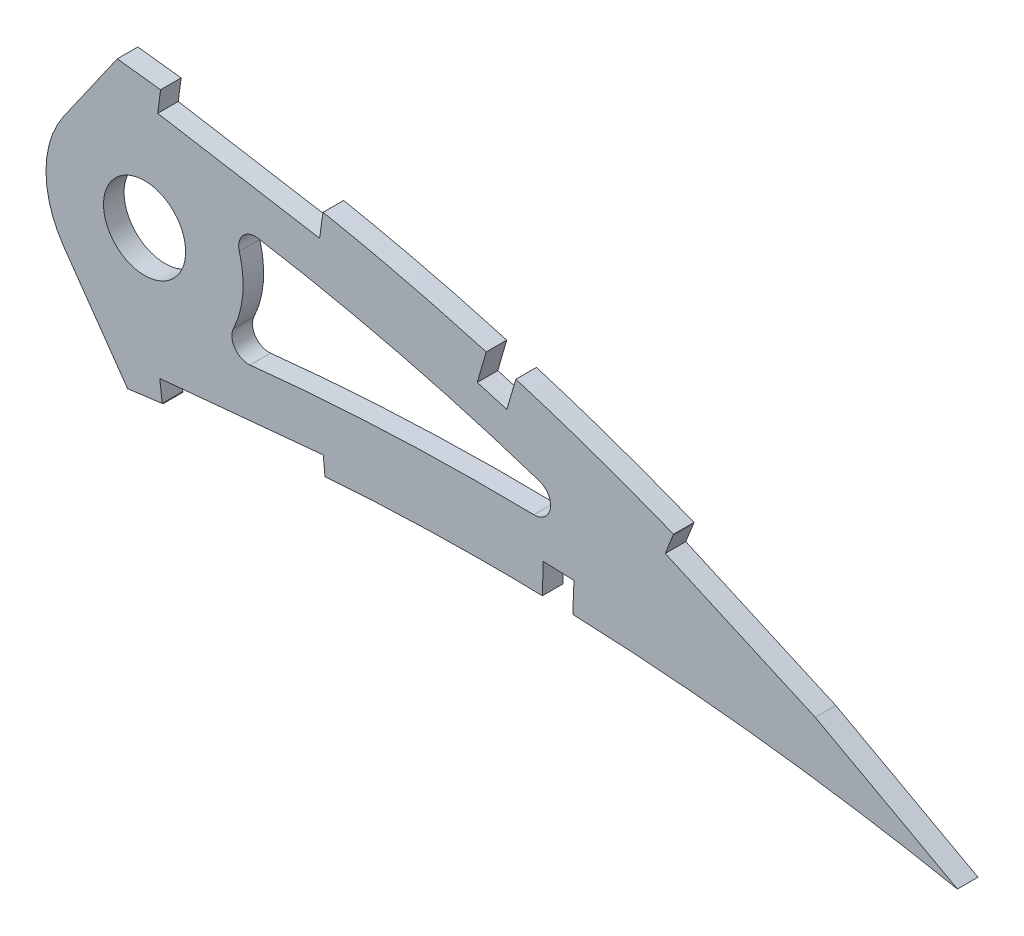
from build123d import *

# Parameters (mm, degrees)
BOSS_EXTRUDE1_DEPTH = 3.175
SKETCH3_R           = 6.35
CUT_EXTRUDE2_DEPTH  = 7.62
CUT_EXTRUDE3_DEPTH  = 425.770685521
CUT_EXTRUDE4_DEPTH  = 425.054471104
FILLET1_R           = 2.54


with BuildPart() as part:
    # Sketch1 → Boss-Extrude1 (new body)
    with BuildSketch(Plane.XY):
        with BuildLine():
            Line((417.491116248, -0.651692804), (421.450974812, -1.472467044))
            Line((421.450974812, -1.472467044), (418.012470552, 0.651692804))
            add(Edge.make_bspline(
                [(418.012470552, 0.651692804), (417.98044815, 0.671474864), (417.852482746, 0.75052638), (417.564153255, 0.927383578), (417.084024874, 1.221948394), (416.411887136, 1.63217468), (415.548261806, 2.156972941), (414.492714479, 2.792668486), (413.245904156, 3.537195961), (411.808132787, 4.387034494), (410.179547234, 5.338203991), (408.360768057, 6.386852134), (406.351953186, 7.52704122), (404.153880987, 8.754112876), (401.767305606, 10.062231026), (399.19267854, 11.445487716), (396.430921499, 12.896846477), (393.483094762, 14.410065077), (390.349735958, 15.976787411), (387.032322118, 17.590492828), (383.53195848, 19.243135295), (379.849840019, 20.925898146), (375.98808191, 22.631921026), (371.947751923, 24.35059805), (367.731152528, 26.074482818), (363.340078768, 27.793764201), (358.777130588, 29.500612257), (354.044068493, 31.183969527), (349.144430575, 32.836479872), (344.080593504, 34.447407706), (338.856178603, 36.008004406), (333.474221444, 37.508151761), (327.939208494, 38.940156234), (322.254650095, 40.293589254), (316.425364207, 41.559391603), (310.455984511, 42.72994226), (304.351517267, 43.793554912), (298.12887857, 44.749400354), (291.888189265, 45.544501897), (285.660339717, 46.324314327), (279.441765017, 47.05687676), (273.147186285, 47.758406613), (266.78265934, 48.424954116), (260.354497207, 49.054435041), (253.869207533, 49.644132572), (247.333529654, 50.192317352), (240.75378784, 50.695883209), (234.13692006, 51.154054264), (227.48946797, 51.562802699), (220.818511901, 51.921821557), (214.130823757, 52.228606963), (207.433363169, 52.481045058), (200.733241899, 52.677611966), (194.03741489, 52.816424499), (187.353132032, 52.896609907), (180.687346008, 52.915977167), (174.047303325, 52.874179852), (167.439957194, 52.769782806), (160.872561498, 52.601356868), (154.352078932, 52.36858769), (147.885560384, 52.071576223), (141.480086041, 51.707835252), (135.142604697, 51.279682727), (128.880173648, 50.78532016), (122.699673543, 50.224616012), (116.607581601, 49.599907517), (110.610680398, 48.90949561), (104.715396798, 48.155344678), (98.928179068, 47.338933301), (93.255520599, 46.45981687), (87.703498103, 45.520534547), (82.278103773, 44.522047456), (76.985077668, 43.467282827), (71.830182495, 42.356515787), (66.818874958, 41.193078409), (61.956363154, 39.97899758), (57.247874135, 38.716495991), (52.698180969, 37.408603084), (48.311884381, 36.058286041), (44.094097756, 34.667028605), (40.048008795, 33.240105797), (36.178587704, 31.778530584), (32.488798598, 30.286805616), (28.982965605, 28.766967771), (25.66370775, 27.223650228), (22.534781646, 25.658610062), (19.59841729, 24.076231981), (16.857562593, 22.478942324), (14.314855879, 20.869707996), (11.971365892, 19.2526108), (9.830323596, 17.628665848), (7.892464518, 16.001976699), (6.159015004, 14.37502038), (4.632452775, 12.748917707), (3.312722951, 11.12653219), (2.201555106, 9.509148701), (1.299141963, 7.898297704), (0.607524637, 6.295149332), (0.126017388, 4.70060514), (-0.137556514, 3.117018659), (-0.203161624, 1.54312034), (-0.067619355, 0.51360488), (0, 0)],
                knots=[0, 0, 0, 0, 0.00025409, 0.001015373, 0.002283359, 0.004056577, 0.006330981, 0.009105275, 0.01237449, 0.016134023, 0.020379661, 0.025105976, 0.030306237, 0.035972206, 0.042099523, 0.048678063, 0.055701664, 0.063160184, 0.071045824, 0.079349826, 0.08806291, 0.097175756, 0.106678112, 0.116561573, 0.126814275, 0.137428301, 0.148393618, 0.15969976, 0.171338125, 0.183297699, 0.195569604, 0.208143556, 0.221011593, 0.234161831, 0.24758745, 0.261276822, 0.27522271, 0.289414144, 0.3037712, 0.317689227, 0.331784111, 0.346039677, 0.36044387, 0.37498272, 0.389640454, 0.404403317, 0.419256601, 0.434186749, 0.449177265, 0.464214782, 0.479284009, 0.49436974, 0.509457833, 0.524532346, 0.53957932, 0.554582984, 0.569529546, 0.584403417, 0.599190992, 0.613876838, 0.628447475, 0.642888675, 0.657186054, 0.671325546, 0.685294014, 0.699078147, 0.712665095, 0.726042645, 0.739197713, 0.752117586, 0.764792042, 0.777208152, 0.789355685, 0.80122396, 0.812803686, 0.824082909, 0.835054602, 0.845709571, 0.856037853, 0.866033834, 0.875688843, 0.884997719, 0.893953426, 0.902552897, 0.910789386, 0.918660734, 0.926166253, 0.933302626, 0.94007122, 0.94647478, 0.952517526, 0.958204819, 0.963546652, 0.9685566, 0.973249913, 0.977651041, 0.981787043, 0.985694226, 0.989415109, 0.993001157, 0.996508416, 1, 1, 1, 1], degree=3))
            add(Edge.make_bspline(
                [(0, 0), (0.107344122, -0.506735851), (0.322525701, -1.522536416), (0.907145976, -2.98486836), (1.680278374, -4.390592942), (2.658149173, -5.735976229), (3.834256448, -7.020650547), (5.206002713, -8.245952015), (6.772042592, -9.411221952), (8.530326502, -10.515929932), (10.478300238, -11.56124868), (12.613774275, -12.546528288), (14.934801506, -13.471460836), (17.438853083, -14.334810006), (20.122867794, -15.137890506), (22.984293745, -15.87874546), (26.019877259, -16.558410209), (29.226698653, -17.175149915), (32.601263508, -17.729591078), (36.140066093, -18.221423529), (39.839474107, -18.650954746), (43.695858135, -19.017283569), (47.705403835, -19.321197808), (51.864114831, -19.562899166), (56.167954337, -19.743154049), (60.612799743, -19.861277173), (65.194297816, -19.919110149), (69.90830817, -19.917521134), (74.750219376, -19.856085207), (79.715895302, -19.738196204), (84.800570833, -19.563107476), (89.999655516, -19.33293774), (95.308459722, -19.050003416), (100.722222022, -18.715263595), (106.236178133, -18.330201822), (111.845540422, -17.897906181), (117.545213296, -17.419454845), (123.330225884, -16.897636702), (129.195456677, -16.33506396), (135.135838219, -15.733517171), (141.146127059, -15.095825988), (147.22096994, -14.424056849), (153.355199033, -13.721793599), (159.543210771, -12.990306925), (165.779772492, -12.233773195), (172.059017171, -11.453637843), (178.375694094, -10.652905812), (184.724121999, -9.835347203), (191.098357706, -9.000868908), (197.493040005, -8.155416157), (203.902002084, -7.29829268), (210.319665377, -6.433906623), (216.740089126, -5.564944849), (223.157019771, -4.691674703), (229.564816603, -3.817715282), (235.957535291, -2.945465763), (242.328914049, -2.075005893), (248.673188486, -1.210662101), (254.983970072, -0.352328891), (261.255439585, 0.498253703), (267.481587275, 1.33854664), (273.656539031, 2.167489343), (279.773925067, 2.98455751), (285.827590721, 3.790057847), (291.72081698, 4.559541474), (297.438204766, 5.333983617), (302.999020517, 5.96885451), (308.4905971, 6.510739718), (313.918638837, 6.955010775), (319.276627913, 7.30805944), (324.558425157, 7.572408429), (329.75773577, 7.751748326), (334.867992319, 7.851399579), (339.882811875, 7.873890942), (344.79534958, 7.826395206), (349.599216077, 7.712740899), (354.287706783, 7.538029372), (358.854280799, 7.308155071), (363.292451785, 7.029384641), (367.595556763, 6.705830062), (371.757599447, 6.34504489), (375.772158368, 5.952310734), (379.633069209, 5.532114413), (383.334698301, 5.093260959), (386.871120866, 4.638639591), (390.237017411, 4.175721536), (393.426969843, 3.709197789), (396.435926147, 3.245024667), (399.259158851, 2.787630174), (401.892107523, 2.343085233), (404.330647739, 1.915543252), (406.570547937, 1.509179531), (408.608700706, 1.129121201), (410.44108076, 0.777256216), (412.065237404, 0.459383467), (413.478150672, 0.176905414), (414.67774925, -0.066198026), (415.661938268, -0.268967448), (416.429222922, -0.428074261), (416.978087732, -0.54377272), (417.307939008, -0.612619163), (417.454496179, -0.643881356), (417.491116248, -0.651692804)],
                knots=[0, 0, 0, 0, 0.003638255, 0.007293231, 0.011028136, 0.014901081, 0.018963272, 0.023258475, 0.027820626, 0.032679082, 0.03785316, 0.043361875, 0.049214679, 0.055422346, 0.061988786, 0.068918036, 0.076211157, 0.083868392, 0.091887411, 0.100265912, 0.108999867, 0.118084529, 0.127514843, 0.13728527, 0.147387917, 0.157816481, 0.168563473, 0.179619128, 0.190977373, 0.202626974, 0.214560478, 0.226767249, 0.239236417, 0.251959004, 0.264923894, 0.278119703, 0.291536035, 0.30516028, 0.318980685, 0.332985499, 0.34716279, 0.361498603, 0.375980747, 0.390597192, 0.405332593, 0.420174823, 0.435109533, 0.450124276, 0.465203068, 0.480333154, 0.495500583, 0.510689775, 0.525887334, 0.541078314, 0.556247233, 0.571381784, 0.58646604, 0.601484516, 0.616424329, 0.631269422, 0.646006524, 0.660620684, 0.675098187, 0.689422858, 0.703581825, 0.716907563, 0.730009275, 0.742952128, 0.755725558, 0.768319952, 0.780724338, 0.792926529, 0.804916041, 0.816679084, 0.828203524, 0.8394749, 0.850481359, 0.861207697, 0.871639326, 0.881763414, 0.891563605, 0.901027365, 0.910138977, 0.918883977, 0.927249278, 0.935221104, 0.942784738, 0.949928188, 0.956638464, 0.962904203, 0.968712288, 0.974054485, 0.978918432, 0.983297218, 0.987180246, 0.990560674, 0.993433357, 0.995790625, 0.997629587, 0.998945816, 0.999736592, 1, 1, 1, 1], degree=3))
        make_face()
    extrude(amount=BOSS_EXTRUDE1_DEPTH)

    # Sketch3 → Cut-Extrude2 (cut)
    with BuildSketch(Plane(origin=(0, 0, 0), x_dir=(-1, 0, 0), z_dir=(0, 0, -1))):
        with Locations((-285.729166098, 26.255421435)):
            Circle(SKETCH3_R)
    extrude(amount=-CUT_EXTRUDE2_DEPTH, mode=Mode.SUBTRACT)

    # Sketch4 → Cut-Extrude3 (cut, through all)
    with BuildSketch(Plane.XY.offset(3.175)):
        with BuildLine():
            ThreePointArc((273.245288943, 17.514116545), (270.489166098, 26.255421435), (273.245288943, 34.996726325))
            Line((273.245288943, 34.996726325), (274.886273897, 37.340295715))
            Line((274.886273897, 37.340295715), (281.517132997, 46.810143922))
            add(Edge.make_bspline(
                [(281.517132997, 46.810143922), (280.833063767, 46.890035279), (278.05111843, 47.211864113), (273.147186285, 47.758406613), (266.78265934, 48.424954116), (260.354497207, 49.054435041), (253.869207533, 49.644132572), (247.333529654, 50.192317352), (240.75378784, 50.695883209), (234.13692006, 51.154054264), (227.48946797, 51.562802699), (220.818511901, 51.921821557), (214.130823757, 52.228606963), (207.433363169, 52.481045058), (200.733241899, 52.677611966), (194.03741489, 52.816424499), (187.353132032, 52.896609907), (180.687346008, 52.915977167), (174.047303325, 52.874179852), (167.439957194, 52.769782806), (160.872561498, 52.601356868), (155.481659891, 52.408911643), (152.280960421, 52.270445439), (151.253871268, 52.223436592)],
                knots=[0.32713491, 0.32713491, 0.32713491, 0.32713491, 0.331784111, 0.346039677, 0.36044387, 0.37498272, 0.389640454, 0.404403317, 0.419256601, 0.434186749, 0.449177265, 0.464214782, 0.479284009, 0.49436974, 0.509457833, 0.524532346, 0.53957932, 0.554582984, 0.569529546, 0.584403417, 0.599190992, 0.613876838, 0.620817468, 0.620817468, 0.620817468, 0.620817468], degree=3))
            add(Edge.make_bspline(
                [(151.253871268, 52.223436592), (150.124766545, 52.171758595), (146.859034641, 52.01328398), (141.480086041, 51.707835252), (135.142604697, 51.279682727), (128.880173648, 50.78532016), (122.699673543, 50.224616012), (116.607581601, 49.599907517), (110.610680398, 48.90949561), (104.715396798, 48.155344678), (98.928179068, 47.338933301), (93.255520599, 46.45981687), (87.703498103, 45.520534547), (82.278103773, 44.522047456), (76.985077668, 43.467282827), (71.830182495, 42.356515787), (66.818874958, 41.193078409), (61.956363154, 39.97899758), (57.247874135, 38.716495991), (52.698180969, 37.408603084), (48.311884381, 36.058286041), (44.094097756, 34.667028605), (40.048008795, 33.240105797), (36.178587704, 31.778530584), (32.488798598, 30.286805616), (28.982965605, 28.766967771), (25.66370775, 27.223650228), (22.534781646, 25.658610062), (19.59841729, 24.076231981), (16.857562593, 22.478942324), (14.314855879, 20.869707996), (11.971365892, 19.2526108), (9.830323596, 17.628665848), (7.892464518, 16.001976699), (6.159015004, 14.37502038), (4.632452775, 12.748917707), (3.312722951, 11.12653219), (2.201555106, 9.509148701), (1.299141963, 7.898297704), (0.607524637, 6.295149332), (0.126017388, 4.70060514), (-0.137556514, 3.117018659), (-0.203161624, 1.54312034), (-0.067619355, 0.51360488), (0, 0)],
                knots=[0.620817468, 0.620817468, 0.620817468, 0.620817468, 0.628447475, 0.642888675, 0.657186054, 0.671325546, 0.685294014, 0.699078147, 0.712665095, 0.726042645, 0.739197713, 0.752117586, 0.764792042, 0.777208152, 0.789355685, 0.80122396, 0.812803686, 0.824082909, 0.835054602, 0.845709571, 0.856037853, 0.866033834, 0.875688843, 0.884997719, 0.893953426, 0.902552897, 0.910789386, 0.918660734, 0.926166253, 0.933302626, 0.94007122, 0.94647478, 0.952517526, 0.958204819, 0.963546652, 0.9685566, 0.973249913, 0.977651041, 0.981787043, 0.985694226, 0.989415109, 0.993001157, 0.996508416, 1, 1, 1, 1], degree=3))
            add(Edge.make_bspline(
                [(0, 0), (0.107344122, -0.506735851), (0.322525701, -1.522536416), (0.907145976, -2.98486836), (1.680278374, -4.390592942), (2.658149173, -5.735976229), (3.834256448, -7.020650547), (5.206002713, -8.245952015), (6.772042592, -9.411221952), (8.530326502, -10.515929932), (10.478300238, -11.56124868), (12.613774275, -12.546528288), (14.934801506, -13.471460836), (17.438853083, -14.334810006), (20.122867794, -15.137890506), (22.984293745, -15.87874546), (26.019877259, -16.558410209), (29.226698653, -17.175149915), (32.601263508, -17.729591078), (36.140066093, -18.221423529), (39.839474107, -18.650954746), (43.695858135, -19.017283569), (47.705403835, -19.321197808), (51.864114831, -19.562899166), (56.167954337, -19.743154049), (60.612799743, -19.861277173), (65.194297816, -19.919110149), (69.90830817, -19.917521134), (74.750219376, -19.856085207), (79.715895302, -19.738196204), (84.800570833, -19.563107476), (89.999655516, -19.33293774), (95.308459722, -19.050003416), (100.722222022, -18.715263595), (106.236178133, -18.330201822), (111.845540422, -17.897906181), (117.545213296, -17.419454845), (123.330225884, -16.897636702), (129.195456677, -16.33506396), (135.135838219, -15.733517171), (141.146127059, -15.095825988), (147.22096994, -14.424056849), (153.355199033, -13.721793599), (159.543210771, -12.990306925), (165.779772492, -12.233773195), (172.059017171, -11.453637843), (176.943047577, -10.834514903), (179.733508183, -10.477064851), (180.418148813, -10.389136696)],
                knots=[0, 0, 0, 0, 0.003638255, 0.007293231, 0.011028136, 0.014901081, 0.018963272, 0.023258475, 0.027820626, 0.032679082, 0.03785316, 0.043361875, 0.049214679, 0.055422346, 0.061988786, 0.068918036, 0.076211157, 0.083868392, 0.091887411, 0.100265912, 0.108999867, 0.118084529, 0.127514843, 0.13728527, 0.147387917, 0.157816481, 0.168563473, 0.179619128, 0.190977373, 0.202626974, 0.214560478, 0.226767249, 0.239236417, 0.251959004, 0.264923894, 0.278119703, 0.291536035, 0.30516028, 0.318980685, 0.332985499, 0.34716279, 0.361498603, 0.375980747, 0.390597192, 0.405332593, 0.420174823, 0.435109533, 0.439965351, 0.439965351, 0.439965351, 0.439965351], degree=3))
            add(Edge.make_bspline(
                [(180.418148813, -10.389136696), (181.850495116, -10.205180963), (185.408545914, -9.745746359), (191.098357706, -9.000868908), (197.493040005, -8.155416157), (203.902002084, -7.29829268), (210.319665377, -6.433906623), (216.740089126, -5.564944849), (223.157019771, -4.691674703), (229.564816603, -3.817715282), (235.957535291, -2.945465763), (242.328914049, -2.075005893), (248.673188486, -1.210662101), (254.983970072, -0.352328891), (261.255439585, 0.498253703), (267.481587275, 1.33854664), (273.656539031, 2.167489343), (278.85986366, 2.862470972), (282.004212477, 3.281215433), (283.108625896, 3.427811537)],
                knots=[0.439965351, 0.439965351, 0.439965351, 0.439965351, 0.450124276, 0.465203068, 0.480333154, 0.495500583, 0.510689775, 0.525887334, 0.541078314, 0.556247233, 0.571381784, 0.58646604, 0.601484516, 0.616424329, 0.631269422, 0.646006524, 0.660620684, 0.675098187, 0.682935578, 0.682935578, 0.682935578, 0.682935578], degree=3))
            Line((283.108625896, 3.427811537), (276.543076139, 12.804388335))
            Line((276.543076139, 12.804388335), (273.245288943, 17.514116545))
        make_face()
        with BuildLine():
            add(Edge.make_bspline(
                [(362.352770137, 17.265342245), (359.116729683, 18.538986422), (350.651628268, 21.70312526), (336.76245738, 26.184380092), (323.325821889, 29.685457962), (312.46520361, 32.017125458), (305.650127669, 33.271885786), (301.010448964, 34.024743586), (299.133105649, 34.309199759), (298.619492426, 34.385432945)],
                knots=[0.130937261, 0.130937261, 0.130937261, 0.130937261, 0.155204367, 0.194005459, 0.23280655, 0.252207096, 0.271607642, 0.281307915, 0.284959903, 0.284959903, 0.284959903, 0.284959903], degree=3))
            ThreePointArc((298.619492426, 34.385432945), (300.369968215, 30.486793952), (300.969166098, 26.255421435))
            ThreePointArc((300.969166098, 26.255421435), (299.795673281, 20.391039483), (296.455914698, 15.429782217))
            add(Edge.make_bspline(
                [(296.455914698, 15.429782217), (296.825227638, 15.475634747), (298.474939021, 15.677515554), (301.393417945, 16.007171577), (306.480644201, 16.530089608), (315.428804381, 17.299112469), (328.220882032, 17.971225759), (343.594122404, 18.103863059), (354.969060254, 17.713169544), (361.214906663, 17.338809272), (362.352770137, 17.265342245)],
                knots=[0.717454935, 0.717454935, 0.717454935, 0.717454935, 0.719982675, 0.728733217, 0.737483758, 0.754984841, 0.789987006, 0.824989172, 0.859991338, 0.867792259, 0.867792259, 0.867792259, 0.867792259], degree=3))
        make_face()
    extrude(amount=-CUT_EXTRUDE3_DEPTH, mode=Mode.SUBTRACT)

    # Sketch5 → Cut-Extrude4 (cut, through all)
    with BuildSketch(Plane.XY.offset(3.175)):
        Polygon((288.173393603, 45.776362445), (287.759757849, 42.628902416), (312.792499178, 38.415705127), (313.227372719, 41.560689534), align=None)
        with BuildLine():
            Line((288.173393603, 45.776362445), (313.227372719, 41.560689534))
            Line((313.227372719, 41.560689534), (313.328431792, 42.161289238))
            add(Edge.make_bspline(
                [(313.328431792, 42.161289238), (312.382989688, 42.346109453), (309.407146517, 42.912686686), (304.351517267, 43.793554912), (298.12887857, 44.749400354), (292.727075643, 45.437622701), (289.410209047, 45.854407815), (288.203335319, 46.004196602)],
                knots=[0.254773896, 0.254773896, 0.254773896, 0.254773896, 0.261276822, 0.27522271, 0.289414144, 0.3037712, 0.31198079, 0.31198079, 0.31198079, 0.31198079], degree=3))
            Line((288.203335319, 46.004196602), (288.173393603, 45.776362445))
        make_face()
        Polygon((338.492483544, 35.871521953), (337.163627429, 31.298701708), (341.736447673, 29.969845589), (343.074959745, 34.500474172), align=None)
        with BuildLine():
            add(Edge.make_bspline(
                [(343.139597857, 34.71926284), (341.727658162, 35.149647278), (340.19883062, 35.603476476), (338.6664674, 36.045065708), (338.55244266, 36.077851486)],
                knots=[0.185605426, 0.185605426, 0.185605426, 0.185605426, 0.195569604, 0.196370508, 0.196370508, 0.196370508, 0.196370508], degree=3))
            Line((338.55244266, 36.077851486), (338.492483544, 35.871521953))
            Line((338.492483544, 35.871521953), (343.074959745, 34.500474172))
            Line((343.074959745, 34.500474172), (343.139597857, 34.71926284))
        make_face()
        with BuildLine():
            Line((369.469556974, 31.05371971), (367.511679068, 26.149795466))
            add(Edge.make_bspline(
                [(418.012470552, 0.651692804), (417.98044815, 0.671474864), (417.852482746, 0.75052638), (417.564153255, 0.927383578), (417.084024874, 1.221948394), (416.411887136, 1.63217468), (415.548261806, 2.156972941), (414.492714479, 2.792668486), (413.245904156, 3.537195961), (411.808132787, 4.387034494), (410.179547234, 5.338203991), (408.360768057, 6.386852134), (406.351953186, 7.52704122), (404.153880987, 8.754112876), (401.767305606, 10.062231026), (399.19267854, 11.445487716), (396.430921499, 12.896846477), (393.483094762, 14.410065077), (390.349735958, 15.976787411), (387.032322118, 17.590492828), (383.53195848, 19.243135295), (379.849840019, 20.925898146), (375.98808191, 22.631921026), (371.947751923, 24.35059805), (369.098573745, 25.515435969), (367.599990275, 26.114537466), (367.511679068, 26.149795466)],
                knots=[0, 0, 0, 0, 0.00025409, 0.001015373, 0.002283359, 0.004056577, 0.006330981, 0.009105275, 0.01237449, 0.016134023, 0.020379661, 0.025105976, 0.030306237, 0.035972206, 0.042099523, 0.048678063, 0.055701664, 0.063160184, 0.071045824, 0.079349826, 0.08806291, 0.097175756, 0.106678112, 0.116561573, 0.126814275, 0.127456175, 0.127456175, 0.127456175, 0.127456175], degree=3))
            Line((418.012470552, 0.651692804), (421.450974812, -1.472467044))
            Line((421.450974812, -1.472467044), (417.491116248, -0.651692804))
            add(Edge.make_bspline(
                [(411.773701593, 0.515858534), (411.894185677, 0.492124414), (412.486090009, 0.375244103), (413.478150672, 0.176905414), (414.67774925, -0.066198026), (415.661938268, -0.268967448), (416.429222922, -0.428074261), (416.978087732, -0.54377272), (417.307939008, -0.612619163), (417.454496179, -0.643881356), (417.491116248, -0.651692804)],
                knots=[0.986316385, 0.986316385, 0.986316385, 0.986316385, 0.987180246, 0.990560674, 0.993433357, 0.995790625, 0.997629587, 0.998945816, 0.999736592, 1, 1, 1, 1], degree=3))
            Line((411.773701593, 0.515858534), (411.720148616, 0.417696682))
            Line((411.720148616, 0.417696682), (430.865990346, -10.027469171))
            Line((430.865990346, -10.027469171), (430.865990346, 31.05371971))
            Line((430.865990346, 31.05371971), (369.469556974, 31.05371971))
        make_face()
        with BuildLine():
            add(Edge.make_bspline(
                [(418.012470552, 0.651692804), (417.98044815, 0.671474864), (417.852482746, 0.75052638), (417.564153255, 0.927383578), (417.084024874, 1.221948394), (416.411887136, 1.63217468), (415.548261806, 2.156972941), (414.492714479, 2.792668486), (413.245904156, 3.537195961), (411.808132787, 4.387034494), (410.179547234, 5.338203991), (408.360768057, 6.386852134), (406.351953186, 7.52704122), (404.153880987, 8.754112876), (401.767305606, 10.062231026), (399.19267854, 11.445487716), (396.430921499, 12.896846477), (393.483094762, 14.410065077), (390.349735958, 15.976787411), (387.032322118, 17.590492828), (383.53195848, 19.243135295), (379.849840019, 20.925898146), (375.98808191, 22.631921026), (371.947751923, 24.35059805), (369.098573745, 25.515435969), (367.599990275, 26.114537466), (367.511679068, 26.149795466)],
                knots=[0, 0, 0, 0, 0.00025409, 0.001015373, 0.002283359, 0.004056577, 0.006330981, 0.009105275, 0.01237449, 0.016134023, 0.020379661, 0.025105976, 0.030306237, 0.035972206, 0.042099523, 0.048678063, 0.055701664, 0.063160184, 0.071045824, 0.079349826, 0.08806291, 0.097175756, 0.106678112, 0.116561573, 0.126814275, 0.127456175, 0.127456175, 0.127456175, 0.127456175], degree=3))
            Line((367.511679068, 26.149795466), (367.404399269, 25.881090251))
            Line((367.404399269, 25.881090251), (366.23090254, 22.931652415))
            Line((366.23090254, 22.931652415), (389.42312198, 12.582016461))
            Line((389.42312198, 12.582016461), (411.408762404, 0.5875759))
            add(Edge.make_bspline(
                [(411.408762404, 0.5875759), (411.530419454, 0.563724257), (411.652066064, 0.539819478), (411.773701593, 0.515858534)],
                knots=[0.985444268, 0.985444268, 0.985444268, 0.985444268, 0.986316385, 0.986316385, 0.986316385, 0.986316385], degree=3))
            add(Edge.make_bspline(
                [(411.773701593, 0.515858534), (411.894185677, 0.492124414), (412.486090009, 0.375244103), (413.478150672, 0.176905414), (414.67774925, -0.066198026), (415.661938268, -0.268967448), (416.429222922, -0.428074261), (416.978087732, -0.54377272), (417.307939008, -0.612619163), (417.454496179, -0.643881356), (417.491116248, -0.651692804)],
                knots=[0.986316385, 0.986316385, 0.986316385, 0.986316385, 0.987180246, 0.990560674, 0.993433357, 0.995790625, 0.997629587, 0.998945816, 0.999736592, 1, 1, 1, 1], degree=3))
            Line((417.491116248, -0.651692804), (421.450974812, -1.472467044))
            Line((421.450974812, -1.472467044), (418.012470552, 0.651692804))
        make_face()
        with BuildLine():
            Line((347.357667083, 12.447189595), (347.23280888, 7.765964376))
            add(Edge.make_bspline(
                [(347.23280888, 7.765964376), (348.034120317, 7.747016773), (349.599907405, 7.704587378), (351.165372129, 7.651632505), (351.929663329, 7.623286365)],
                knots=[0.833836361, 0.833836361, 0.833836361, 0.833836361, 0.8394749, 0.844855139, 0.844855139, 0.844855139, 0.844855139], degree=3))
            Line((351.929663329, 7.623286365), (352.115562741, 12.256221389))
            Line((352.115562741, 12.256221389), (347.357667083, 12.447189595))
        make_face()
        with BuildLine():
            Line((288.465231112, 4.138919143), (288.587869755, 4.150554153))
            add(Edge.make_bspline(
                [(288.587869755, 4.150554153), (289.671211047, 4.292971088), (292.6325763, 4.683042777), (297.438204766, 5.333983617), (302.999020517, 5.96885451), (308.381857346, 6.500009746), (311.916399264, 6.791077994), (313.61817292, 6.918331171)],
                knots=[0.695895227, 0.695895227, 0.695895227, 0.695895227, 0.703581825, 0.716907563, 0.730009275, 0.742952128, 0.754956915, 0.754956915, 0.754956915, 0.754956915], degree=3))
            Line((313.61817292, 6.918331171), (313.354800628, 9.688404893))
            Line((313.354800628, 9.688404893), (288.076909853, 7.289993937))
            Line((288.076909853, 7.289993937), (288.465231112, 4.138919143))
        make_face()
    extrude(amount=-CUT_EXTRUDE4_DEPTH, mode=Mode.SUBTRACT)

    # Fillet1
    fillet1_edges = [part.edges().sort_by_distance(p)[0] for p in [
        (362.352770137, 17.265342245, 1.5875),
        (296.455914698, 15.429782217, 1.5875),
        (298.619492426, 34.385432945, 1.5875),
    ]]
    fillet(fillet1_edges, radius=FILLET1_R)


solid = part.part
